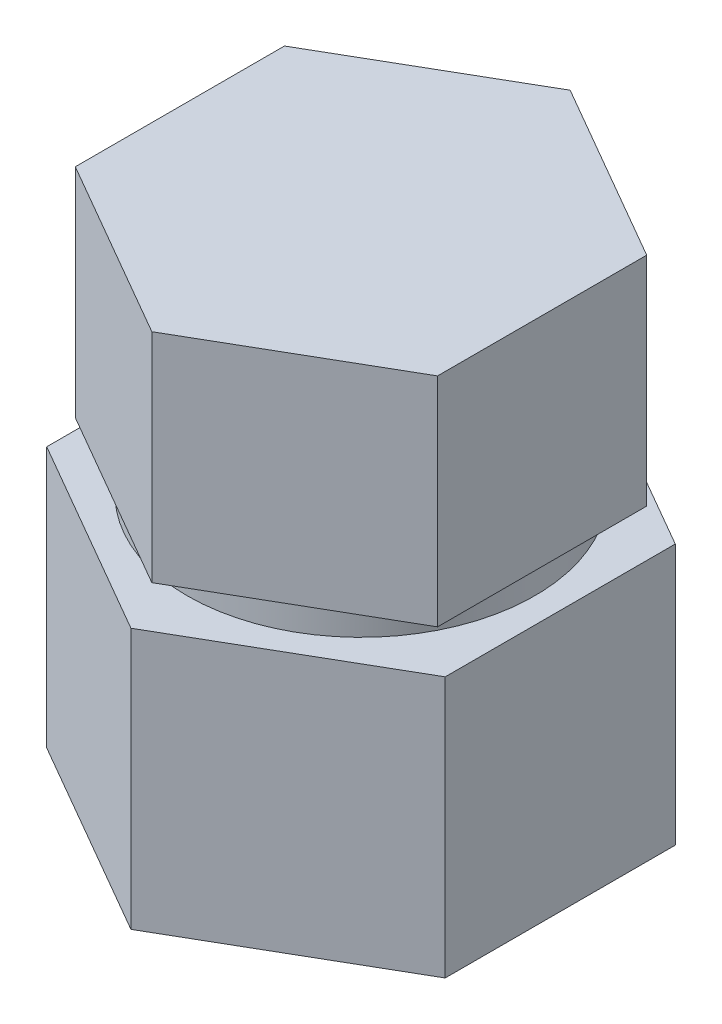
from build123d import *

# Parameters (mm, degrees)
EXTRUDE_1_DEPTH = 3
SKETCH_3_R      = 2.4
EXTRUDE_2_DEPTH = 0.4
EXTRUDE_3_DEPTH = 3.6


with BuildPart() as part:
    # 草图2 → 凸台-拉伸1 (new body)
    with BuildSketch(Plane(origin=(0, 0, 0), x_dir=(1, 0, 0), z_dir=(0, 1, 0))):
        Polygon((0, -2.886751346), (2.5, -1.443375673), (2.5, 1.443375673), (0, 2.886751346), (-2.5, 1.443375673), (-2.5, -1.443375673), align=None)
    extrude(amount=-EXTRUDE_1_DEPTH)

    # 草图3 → 凸台-拉伸2 (add)
    with BuildSketch(Plane.XZ.offset(3)):
        Circle(SKETCH_3_R)
    extrude(amount=EXTRUDE_2_DEPTH)

    # 草图4 → 凸台-拉伸3 (add)
    with BuildSketch(Plane.XZ.offset(3.4)):
        Polygon((0, -3.175426481), (2.75, -1.58771324), (2.75, 1.58771324), (0, 3.175426481), (-2.75, 1.58771324), (-2.75, -1.58771324), align=None)
    extrude(amount=EXTRUDE_3_DEPTH)


solid = part.part
